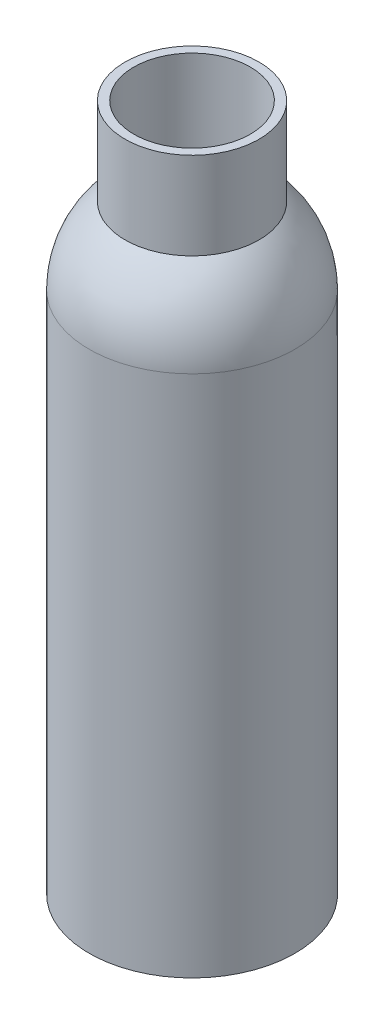
from build123d import *


with BuildPart() as part:
    # Sketch3 → Revolve1 (revolve)
    with BuildSketch(Plane.XY):
        with BuildLine():
            Line((0, 0), (37.465, 0))
            Line((37.465, 0), (37.465, 190.5))
            ThreePointArc((37.465, 190.5), (34.032849621, 205.925272777), (24.384, 218.44))
            Line((24.384, 218.44), (24.384, 250.19))
            Line((24.384, 250.19), (21.209, 250.19))
            Line((21.209, 250.19), (21.209, 218.44))
            ThreePointArc((21.209, 218.44), (31.341590564, 204.463946967), (34.925, 187.577306486))
            Line((34.925, 187.577306486), (34.925, 3.175))
            Line((34.925, 3.175), (0, 3.175))
            Line((0, 3.175), (0, 0))
        make_face()
    revolve(axis=Axis((0, 0, 0), (0, 1, 0)))


solid = part.part
